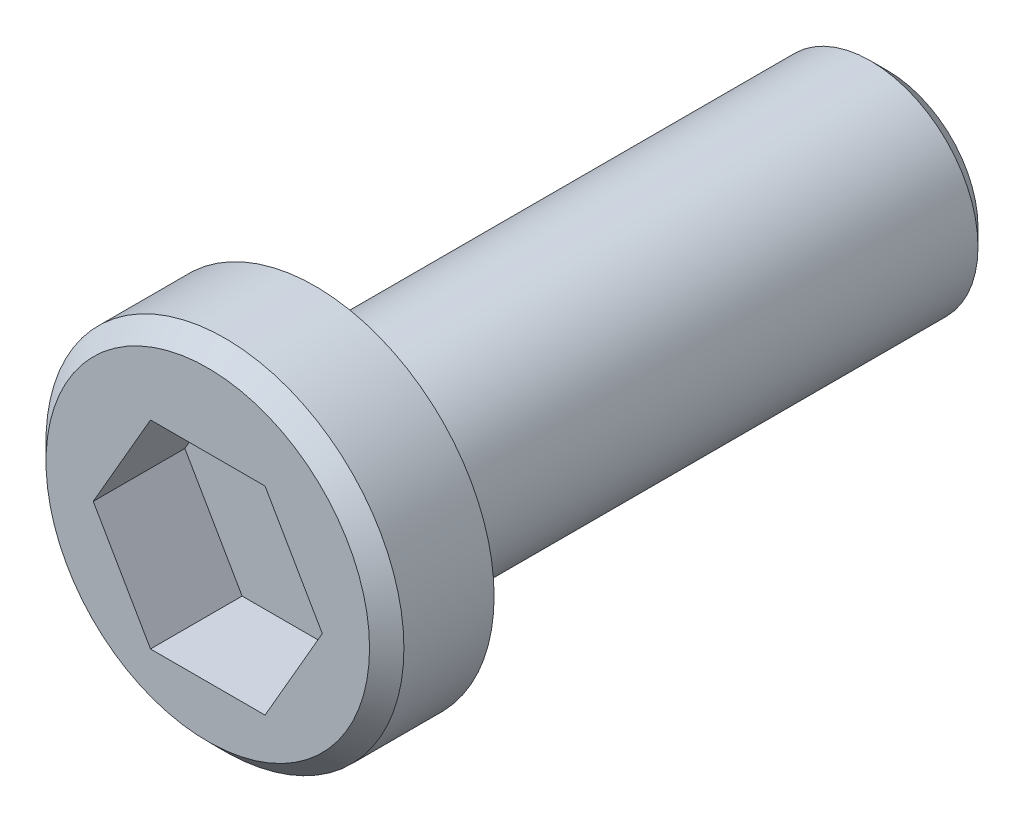
from build123d import *

# Parameters (mm, degrees)
SKETCH1_R          = 4.7625
EXTRUDE1_DEPTH     = 25.4
SKETCH3_R          = 7.9375
EXTRUDE3_DEPTH     = 4.7625
CHAMFER1_SIZE      = 0.762
CUT_EXTRUDE1_DEPTH = 4.064


with BuildPart() as part:
    # Sketch1 → Extrude1 (new body)
    with BuildSketch(Plane.XY):
        Circle(SKETCH1_R)
    extrude(amount=EXTRUDE1_DEPTH)

    # Sketch3 → Extrude3 (add)
    with BuildSketch(Plane.XY.offset(25.4)):
        with Locations((0, 0.491553118)):
            Circle(SKETCH3_R)
    extrude(amount=EXTRUDE3_DEPTH)

    # Chamfer1
    chamfer1_edges = [part.edges().sort_by_distance(p)[0] for p in [
        (-7.9375, 0.491553118, 30.1625),
        (-4.7625, 0, 0),
    ]]
    chamfer(chamfer1_edges, length=CHAMFER1_SIZE)

    # Sketch4 → Cut-Extrude1 (cut)
    with BuildSketch(Plane.XY.offset(30.1625)):
        Polygon((5.08, 0), (2.54, 4.399409051), (-2.54, 4.399409051), (-5.08, 0), (-2.54, -4.399409051), (2.54, -4.399409051), align=None)
    extrude(amount=-CUT_EXTRUDE1_DEPTH, mode=Mode.SUBTRACT)


solid = part.part
